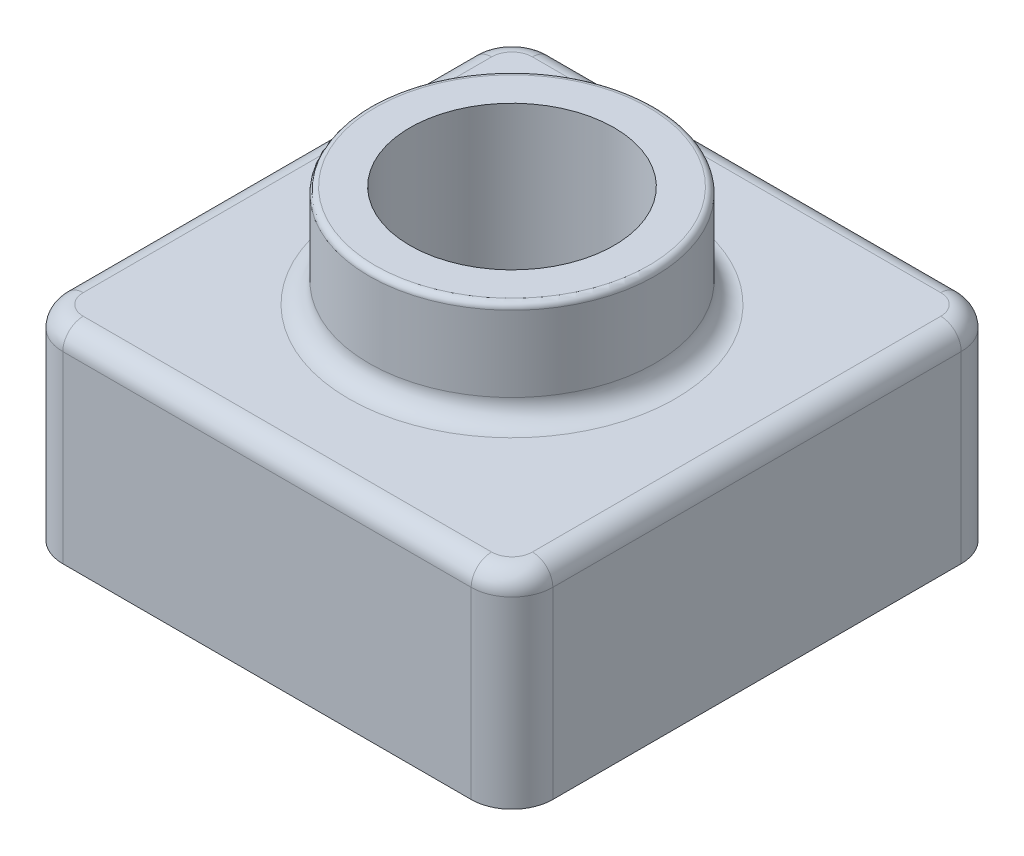
from build123d import *

# Parameters (mm, degrees)
SKETCH1_W           = 120
SKETCH1_H           = 120
BOSS_EXTRUDE1_DEPTH = 50
SKETCH2_R           = 35
BOSS_EXTRUDE2_DEPTH = 25
SKETCH4_R           = 25
CUT_EXTRUDE4_DEPTH  = 132.903810889
FILLET3_R           = 10
FILLET5_R           = 1.5
FILLET6_R           = 5
SHELL3_T            = -2


with BuildPart() as part:
    # Sketch1 → Boss-Extrude1 (new body)
    with BuildSketch(Plane(origin=(0, 0, 0), x_dir=(1, 0, 0), z_dir=(0, 1, 0))):
        with Locations((12.380408942, -20.837440141)):
            Rectangle(SKETCH1_W, SKETCH1_H)
    extrude(amount=BOSS_EXTRUDE1_DEPTH)

    # Sketch2 → Boss-Extrude2 (add)
    with BuildSketch(Plane(origin=(0, 50, 0), x_dir=(1, 0, 0), z_dir=(0, 1, 0))):
        with Locations(Location((12.380408942, -20.837440141, 0), (0, 0, 270))):
            Circle(SKETCH2_R)
    extrude(amount=BOSS_EXTRUDE2_DEPTH)

    # Sketch4 → Cut-Extrude4 (cut, through all)
    with BuildSketch(Plane(origin=(0, 75, 0), x_dir=(1, 0, 0), z_dir=(0, 1, 0))):
        with Locations(Location((12.380408942, -20.837440141, 0), (0, 0, 270))):
            Circle(SKETCH4_R)
    extrude(amount=-CUT_EXTRUDE4_DEPTH, mode=Mode.SUBTRACT)

    # Fillet3
    fillet3_edges = [part.edges().sort_by_distance(p)[0] for p in [
        (-47.619591058, 25, -39.162559859),
        (72.380408942, 25, -39.162559859),
        (72.380408942, 25, 80.837440141),
        (-47.619591058, 25, 80.837440141),
    ]]
    fillet(fillet3_edges, radius=FILLET3_R)

    # Fillet5
    fillet5_edges = [part.edges().sort_by_distance(p)[0] for p in [
        (12.380408942, 75, -14.162559859),
    ]]
    fillet(fillet5_edges, radius=FILLET5_R)

    # Fillet6
    fillet6_edges = [part.edges().sort_by_distance(p)[0] for p in [
        (12.380408942, 50, -14.162559859),
        (12.380408942, 50, 80.837440141),
        (-47.619591058, 50, 20.837440141),
        (72.380408942, 50, 20.837440141),
        (12.380408942, 50, -39.162559859),
        (69.451476754, 50, -36.233627671),
        (69.451476754, 50, 77.908507953),
        (-44.69065887, 50, -36.233627671),
        (-44.69065887, 50, 77.908507953),
    ]]
    fillet(fillet6_edges, radius=FILLET6_R)

    # Shell3
    shell3_openings = [part.faces().sort_by_distance(p)[0] for p in [
        (12.380408942, 0, -37.465503584),
    ]]
    offset(amount=SHELL3_T, openings=shell3_openings, kind=Kind.INTERSECTION)


solid = part.part
